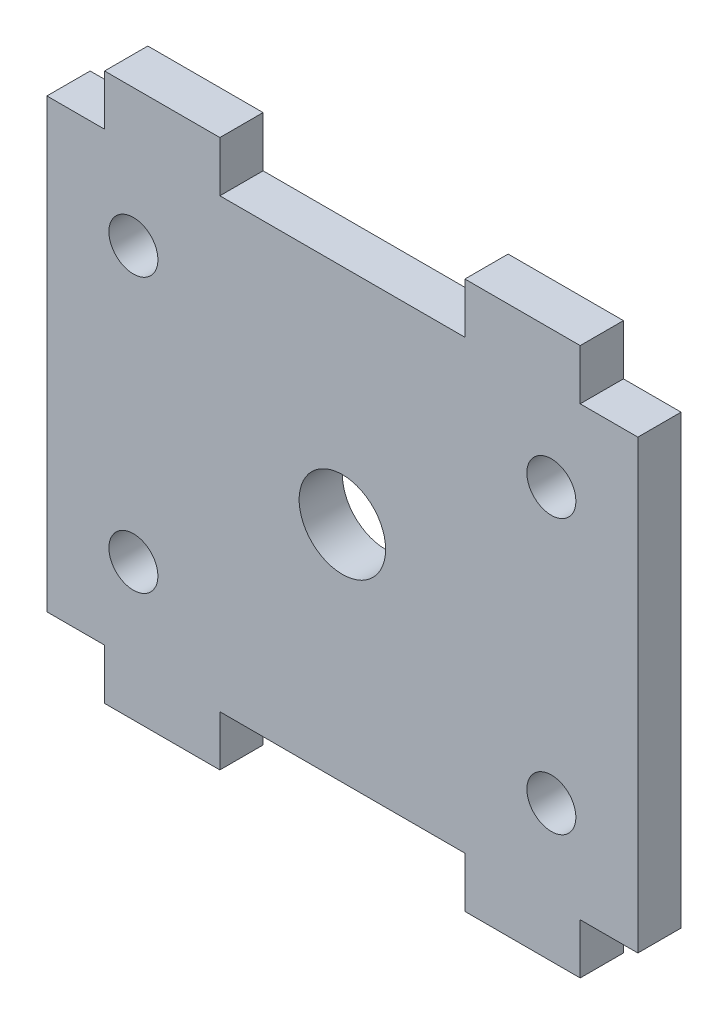
from build123d import *

# Parameters (mm, degrees)
BOSS_EXTRUDE1_DEPTH          = 3
F_6_0_6_DIAMETER_HOLE1_D     = 6
F_6_0_6_DIAMETER_HOLE1_DEPTH = 3
M3_CLEARANCE_HOLE1_D         = 3.4
M3_CLEARANCE_HOLE1_DEPTH     = 3.001
MIRROR2_COPY_1_D             = 3.4
MIRROR2_COPY_1_DEPTH         = 3.001


with BuildPart() as part:
    # Sketch1 → Boss-Extrude1 (new body)
    with BuildSketch(Plane.XY):
        Polygon((20.5, -15.5), (20.5, 15.5), (16.5, 15.5), (16.5, 19), (8.5, 19), (8.5, 15.5), (-8.5, 15.5), (-8.5, 19), (-16.5, 19), (-16.5, 15.5), (-20.5, 15.5), (-20.5, -15.5), (-16.5, -15.5), (-16.5, -19), (-8.5, -19), (-8.5, -15.5), (8.5, -15.5), (8.5, -19), (16.5, -19), (16.5, -15.5), align=None)
    extrude(amount=BOSS_EXTRUDE1_DEPTH)

    # Ø6.0 (6) Diameter Hole1
    with Locations(Plane.XY.offset(3)):
        with Locations((0, 0)):
            Hole(F_6_0_6_DIAMETER_HOLE1_D / 2, depth=F_6_0_6_DIAMETER_HOLE1_DEPTH)

    # M3 Clearance Hole1
    with Locations(Plane.XY.offset(3)):
        with Locations((14.5, 9.5)):
            m3_clearance_hole1 = Hole(M3_CLEARANCE_HOLE1_D / 2, depth=M3_CLEARANCE_HOLE1_DEPTH)

    # Mirror1: M3 Clearance Hole1 across plane
    add(m3_clearance_hole1.mirror(Plane(origin=(0, 0, 0), x_dir=(0, 0, 1), z_dir=(1, 0, 0))), mode=Mode.SUBTRACT)

    # Mirror2: M3 Clearance Hole1 across plane
    add(m3_clearance_hole1.mirror(Plane.ZX), mode=Mode.SUBTRACT)

    # Mirror2 copy 1
    with Locations(Plane(origin=(0, 0, 3), x_dir=(-1, 0, 0), z_dir=(0, 0, 1))):
        with Locations((14.5, 9.5)):
            Hole(MIRROR2_COPY_1_D / 2, depth=MIRROR2_COPY_1_DEPTH)


solid = part.part
